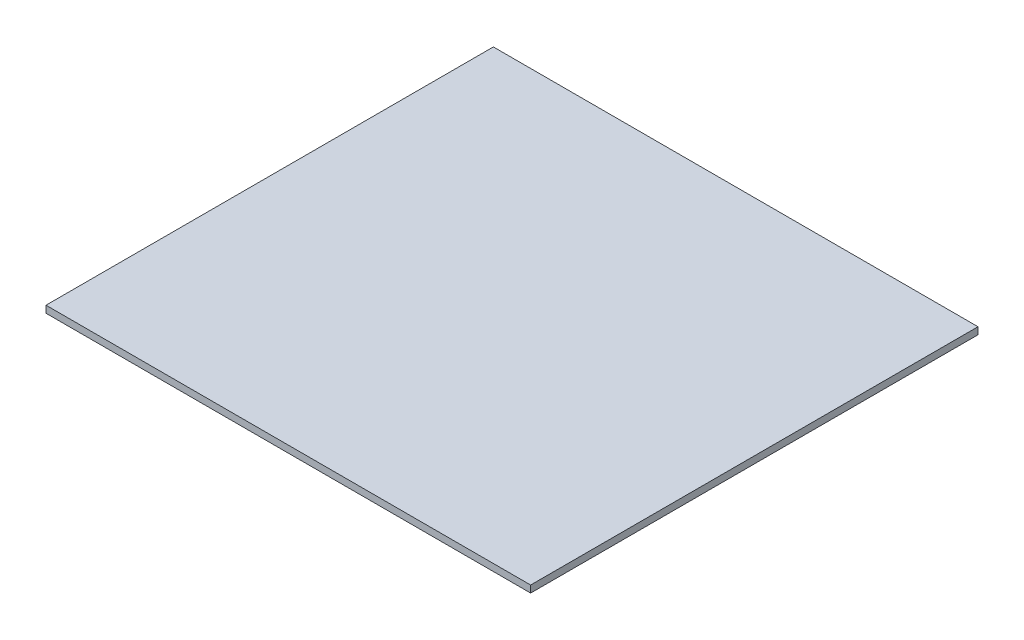
from build123d import *

# Parameters (mm, degrees)
SKETCH1_W           = 330.2
SKETCH1_H           = 304.8
BOSS_EXTRUDE1_DEPTH = 4.7625


with BuildPart() as part:
    # Sketch1 → Boss-Extrude1 (new body)
    with BuildSketch(Plane(origin=(0, 0, 0), x_dir=(1, 0, 0), z_dir=(0, 1, 0))):
        with Locations((165.1, -152.4)):
            Rectangle(SKETCH1_W, SKETCH1_H)
    extrude(amount=BOSS_EXTRUDE1_DEPTH)


solid = part.part
